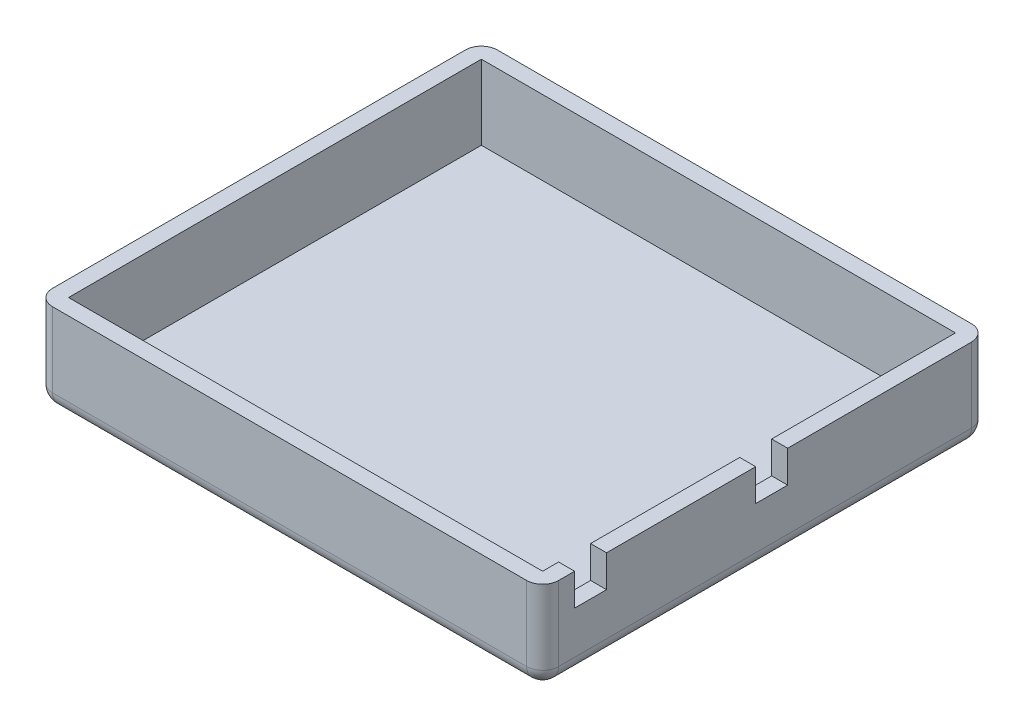
from build123d import *

# Parameters (mm, degrees)
SKETCH1_W           = 95
SKETCH1_H           = 83.5
SKETCH1_W_2         = 89
SKETCH1_H_2         = 77.5
BOSS_EXTRUDE1_DEPTH = 3
SKETCH1_3_W         = 95
SKETCH1_3_H         = 83.5
SKETCH1_3_W_2       = 89
SKETCH1_3_H_2       = 77.5
BOSS_EXTRUDE2_DEPTH = 17
CUT_EXTRUDE1_REACH  = 97
SKETCH2_W           = 6
SKETCH2_H           = 6
FILLET1_R           = 3


with BuildPart() as part:
    # Sketch1 → Boss-Extrude1 (new body)
    with BuildSketch(Plane(origin=(0, 0, 0), x_dir=(1, 0, 0), z_dir=(0, 1, 0))):
        Rectangle(SKETCH1_W, SKETCH1_H)
        Rectangle(SKETCH1_W_2, SKETCH1_H_2, mode=Mode.SUBTRACT)
        Rectangle(SKETCH1_W_2, SKETCH1_H_2)
    extrude(amount=BOSS_EXTRUDE1_DEPTH)

    # Sketch1_3 → Boss-Extrude2 (add)
    with BuildSketch(Plane(origin=(0, 0, 0), x_dir=(1, 0, 0), z_dir=(0, 1, 0))):
        Rectangle(SKETCH1_3_W, SKETCH1_3_H)
        Rectangle(SKETCH1_3_W_2, SKETCH1_3_H_2, mode=Mode.SUBTRACT)
    extrude(amount=BOSS_EXTRUDE2_DEPTH)

    # Sketch2 → Cut-Extrude1 (cut, up to next)
    with BuildSketch(Plane(origin=(47.5, 0, 0), x_dir=(0, 0, -1), z_dir=(1, 0, 0)), mode=Mode.PRIVATE) as cut_extrude1_sk1:
        with Locations((-32.75, 14)):
            Rectangle(SKETCH2_W, SKETCH2_H)
    cut_extrude1_tool1 = extrude(cut_extrude1_sk1.sketch, amount=-CUT_EXTRUDE1_REACH, mode=Mode.PRIVATE) & part.part
    add(cut_extrude1_tool1.solids().sort_by_distance((47.5, 14, 32.75))[0], mode=Mode.SUBTRACT)
    # Sketch2 → Cut-Extrude1 (cut, up to next)
    with BuildSketch(Plane(origin=(47.5, 0, 0), x_dir=(0, 0, -1), z_dir=(1, 0, 0)), mode=Mode.PRIVATE) as cut_extrude1_sk2:
        with Locations((1.25, 14)):
            Rectangle(SKETCH2_W, SKETCH2_H)
    cut_extrude1_tool2 = extrude(cut_extrude1_sk2.sketch, amount=-CUT_EXTRUDE1_REACH, mode=Mode.PRIVATE) & part.part
    add(cut_extrude1_tool2.solids().sort_by_distance((47.5, 14, -1.25))[0], mode=Mode.SUBTRACT)

    # Fillet1
    fillet1_edges = [part.edges().sort_by_distance(p)[0] for p in [
        (-47.5, 0, 0),
        (0, 0, -41.75),
        (47.5, 0, 0),
        (0, 0, 41.75),
        (-47.5, 8.5, 41.75),
        (-47.5, 8.5, -41.75),
        (47.5, 8.5, -41.75),
        (47.5, 8.5, 41.75),
    ]]
    fillet(fillet1_edges, radius=FILLET1_R)


solid = part.part
